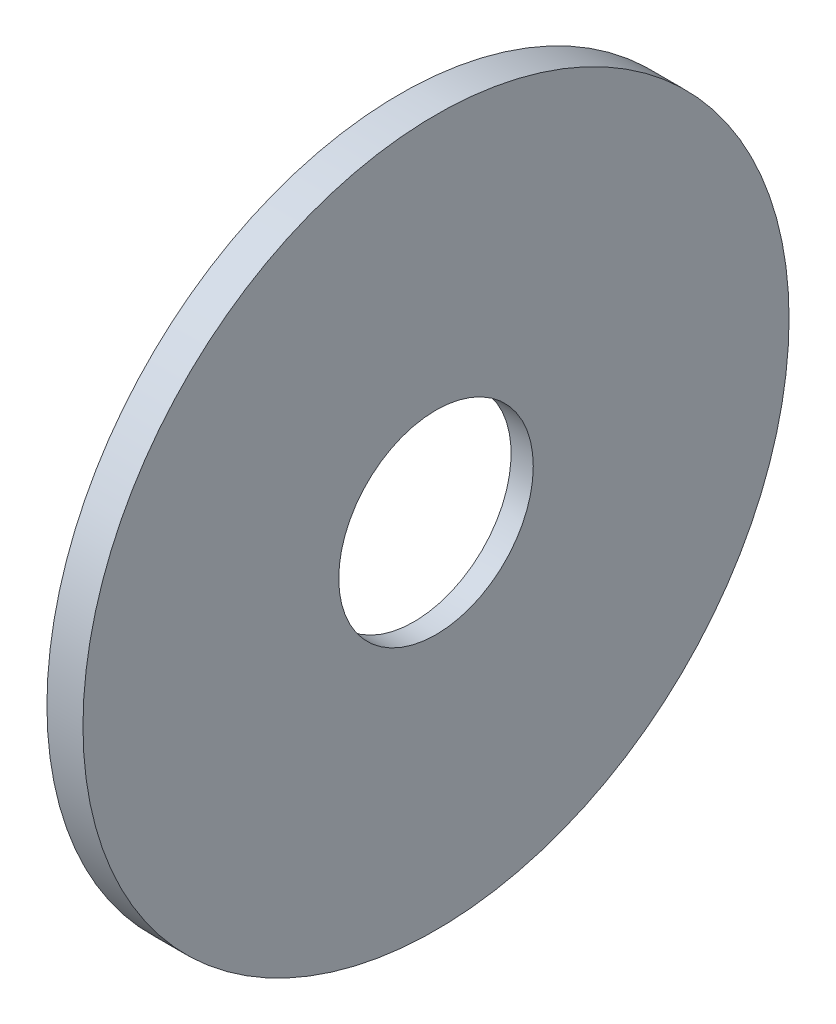
from build123d import *

# Parameters (mm, degrees)
SKETCH1_R           = 49
SKETCH1_R_2         = 13.5
BOSS_EXTRUDE1_DEPTH = 5


with BuildPart() as part:
    # Sketch1 → Boss-Extrude1 (new body)
    with BuildSketch(Plane(origin=(0, 0, 0), x_dir=(0, 0, -1), z_dir=(1, 0, 0))):
        Circle(SKETCH1_R)
        Circle(SKETCH1_R_2, mode=Mode.SUBTRACT)
    extrude(amount=BOSS_EXTRUDE1_DEPTH)

    # Sketch3 → Cut-Revolve1 (revolve, cut)
    with BuildSketch(Plane.XY):
        with BuildLine():
            Line((0, 0), (2, 0))
            ThreePointArc((2, 0), (1.592509761, 24.524184072), (0, 49))
            Line((0, 49), (0, 0))
        make_face()
    revolve(axis=Axis((0, 0, 0), (1, 0, 0)), mode=Mode.SUBTRACT)


solid = part.part
